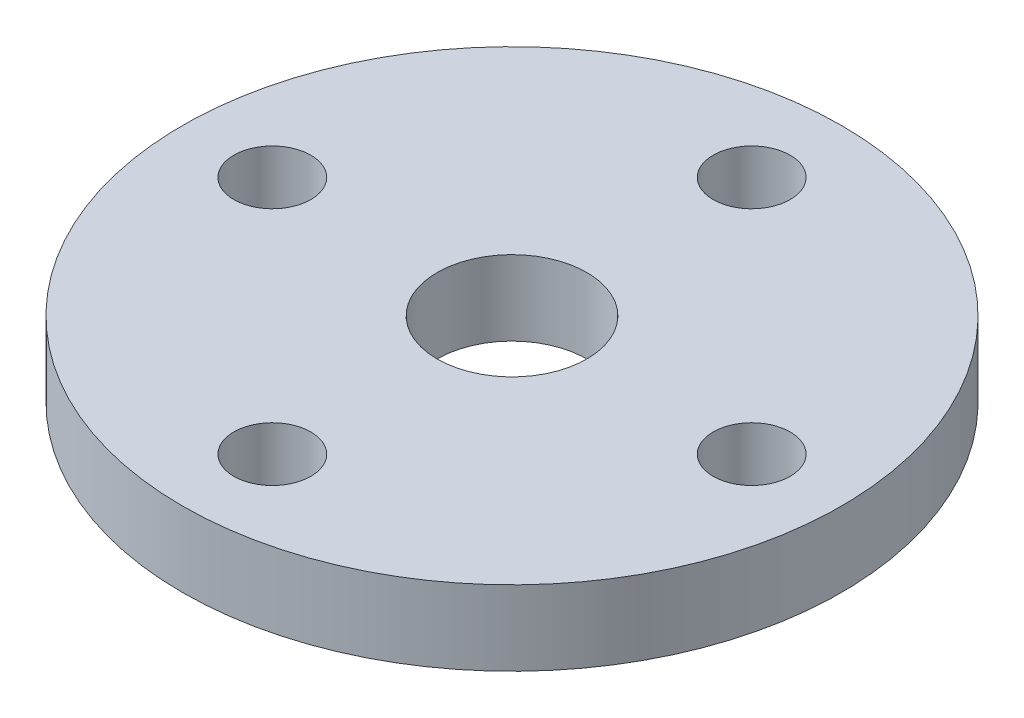
from build123d import *

# Parameters (mm, degrees)
SKETCH1_R           = 13.97
BOSS_EXTRUDE1_DEPTH = 3.175
SKETCH2_R           = 3.175
CUT_EXTRUDE1_DEPTH  = 3.175
CIRPATTERN1_COUNT   = 4


with BuildPart() as part:
    # Sketch1 → Boss-Extrude1 (new body)
    with BuildSketch(Plane(origin=(0, 0, 0), x_dir=(1, 0, 0), z_dir=(0, 1, 0))):
        Circle(SKETCH1_R)
    extrude(amount=BOSS_EXTRUDE1_DEPTH)

    # Sketch2 → Cut-Extrude1 (cut)
    with BuildSketch(Plane(origin=(0, 3.175, 0), x_dir=(1, 0, 0), z_dir=(0, 1, 0))):
        Circle(SKETCH2_R)
    extrude(amount=-CUT_EXTRUDE1_DEPTH, mode=Mode.SUBTRACT)

    # Sketch3 → #4 Clearance Hole1 (revolve, cut)
    with BuildSketch(Plane(origin=(0, 3.175, -10.16), x_dir=(0, 0, 1), z_dir=(1, 0, 0))):
        Polygon((0, 0), (0, 11.140574487), (1.63195, 10.16), (1.63195, 0), align=None)
    f_4_clearance_hole1 = revolve(axis=Axis((0, 9.525, -10.16), (0, -1, 0)), mode=Mode.SUBTRACT)

    # CirPattern1: #4 Clearance Hole1 ×4 about axis
    cirpattern1_axis = Axis((0, 0, 0), (0, 1, 0))
    for i in range(1, CIRPATTERN1_COUNT):
        add(f_4_clearance_hole1.rotate(cirpattern1_axis, i * 360 / CIRPATTERN1_COUNT), mode=Mode.SUBTRACT)


solid = part.part
